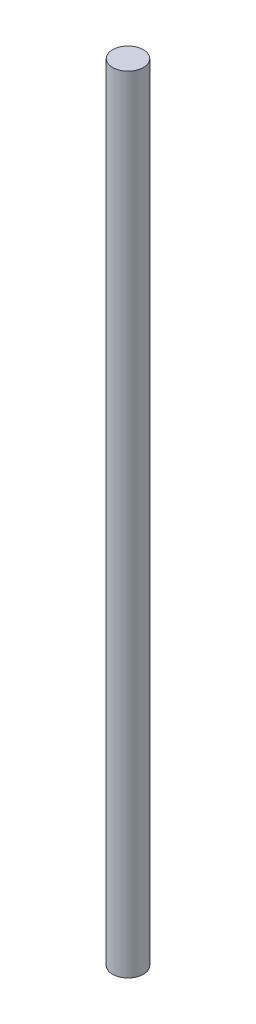
from build123d import *

# Parameters (mm, degrees)
SKETCH1_R                       = 3.175
BOSS_EXTRUDE1_DEPTH             = 161.925
F_32_0_116_DIAMETER_HOLE2_D     = 2.9464
F_32_0_116_DIAMETER_HOLE2_DEPTH = 3.6576
F_32_0_116_DIAMETER_HOLE2_TIP   = 0.885187864


with BuildPart() as part:
    # Sketch1 → Boss-Extrude1 (new body)
    with BuildSketch(Plane(origin=(0, 0, 0), x_dir=(1, 0, 0), z_dir=(0, 1, 0))):
        Circle(SKETCH1_R)
    extrude(amount=BOSS_EXTRUDE1_DEPTH)

    # #32 (0.116) Diameter Hole2
    with Locations(Plane(origin=(0, 0, 0), x_dir=(-1, 0, 0), z_dir=(0, -1, 0))):
        with Locations((0, 0)):
            Hole(F_32_0_116_DIAMETER_HOLE2_D / 2, depth=F_32_0_116_DIAMETER_HOLE2_DEPTH)
            with Locations((0, 0, -(F_32_0_116_DIAMETER_HOLE2_DEPTH + F_32_0_116_DIAMETER_HOLE2_TIP / 2))):  # 118° drill point
                Cone(0, F_32_0_116_DIAMETER_HOLE2_D / 2, F_32_0_116_DIAMETER_HOLE2_TIP, mode=Mode.SUBTRACT)


solid = part.part
